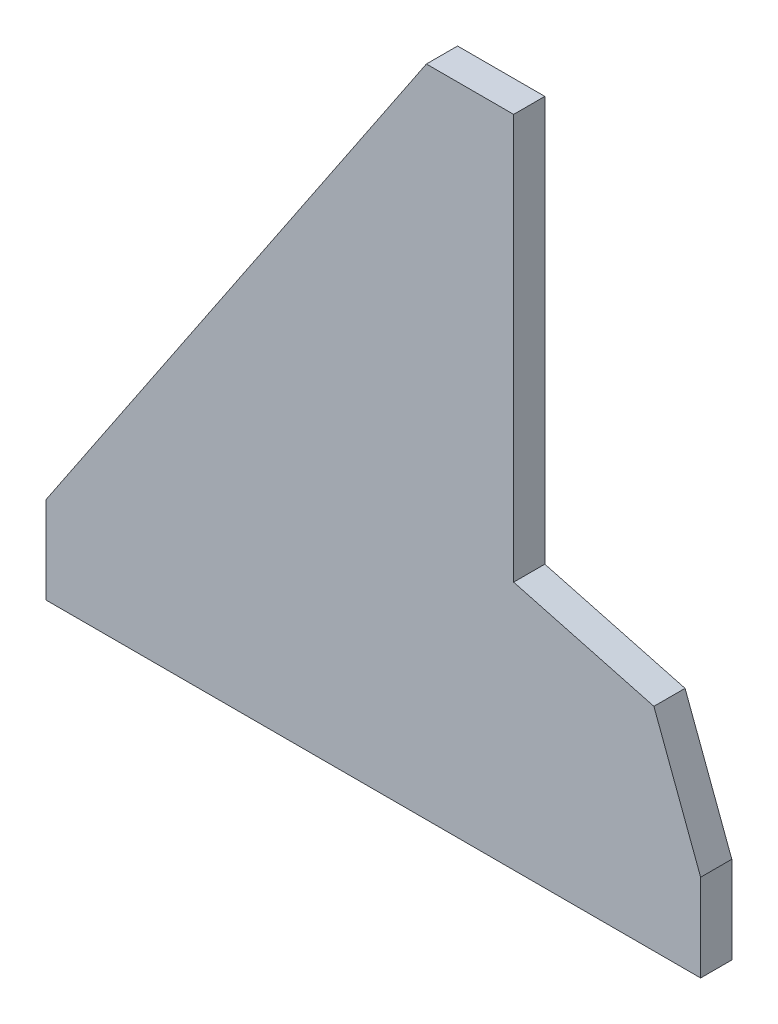
from build123d import *

# Parameters (mm, degrees)
Y_KSEKLIK_EKSTR_ZYON1_DEPTH = 10


with BuildPart() as part:
    # Çizim1 → Yükseklik-Ekstrüzyon1 (new body)
    with BuildSketch(Plane.XY):
        Polygon((-210, 28), (-210, 0), (0, 0), (0, 28), (-15, 68), (-60, 80), (-60, 210), (-88, 210), align=None)
    extrude(amount=Y_KSEKLIK_EKSTR_ZYON1_DEPTH)


solid = part.part
